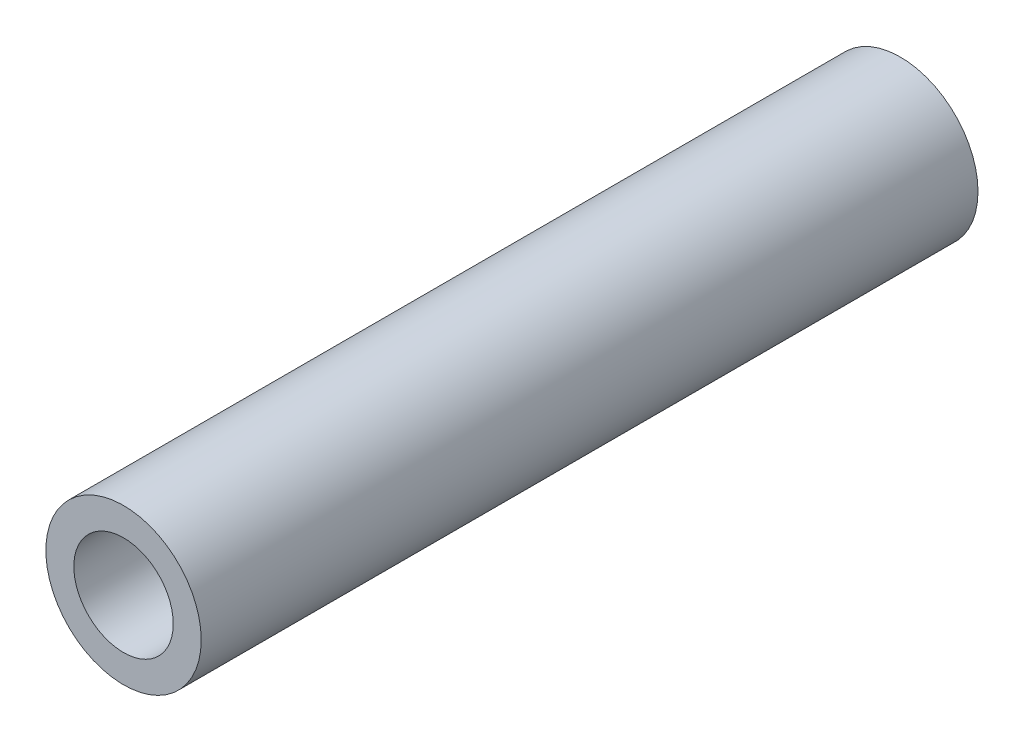
from build123d import *

# Parameters (mm, degrees)
SKETCH1_R           = 2.5
SKETCH1_R_2         = 1.6
BOSS_EXTRUDE1_DEPTH = 25


with BuildPart() as part:
    # Sketch1 → Boss-Extrude1 (new body)
    with BuildSketch(Plane.XY):
        Circle(SKETCH1_R)
        Circle(SKETCH1_R_2, mode=Mode.SUBTRACT)
    extrude(amount=BOSS_EXTRUDE1_DEPTH)


solid = part.part
